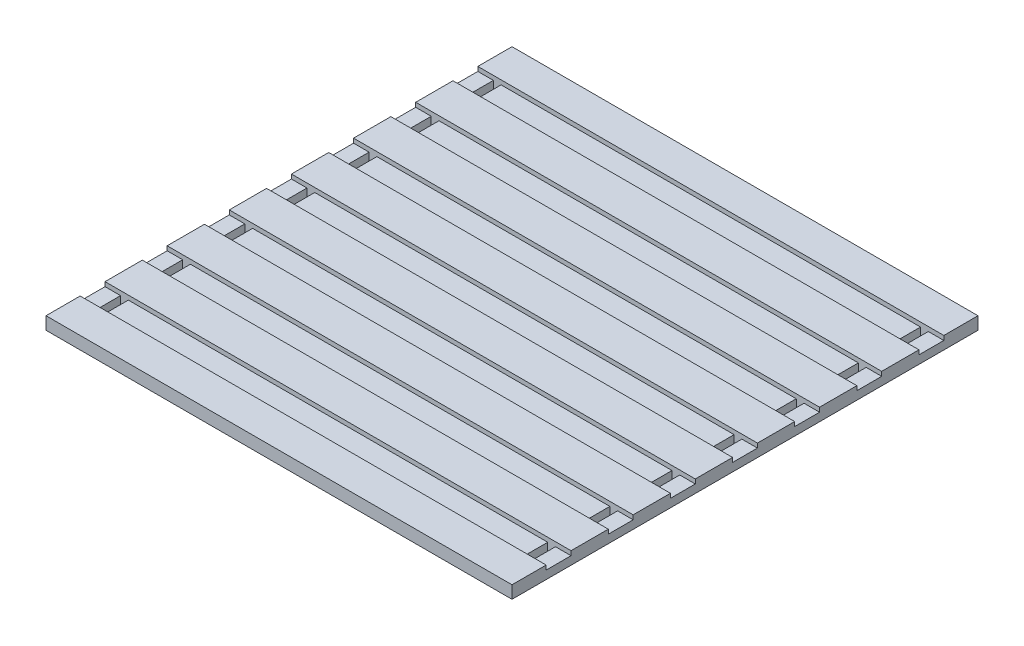
from build123d import *

# Parameters (mm, degrees)
SKETCH1_W           = 190.5
SKETCH1_H           = 190.5
BOSS_EXTRUDE1_DEPTH = 5.159375
SKETCH2_W           = 190.5
SKETCH2_H           = 10.16
CUT_EXTRUDE1_DEPTH  = 1.778
SKETCH3_W           = 3.175
SKETCH3_H           = 10.16
CUT_EXTRUDE3_DEPTH  = 4.381375
LPATTERN1_COUNT     = 7
LPATTERN1_PITCH     = 25.4


with BuildPart() as part:
    # Sketch1 → Boss-Extrude1 (new body)
    with BuildSketch(Plane(origin=(0, 0, 0), x_dir=(1, 0, 0), z_dir=(0, 1, 0))):
        Rectangle(SKETCH1_W, SKETCH1_H)
    extrude(amount=BOSS_EXTRUDE1_DEPTH)

    # Sketch2 → Cut-Extrude1 (cut)
    with BuildSketch(Plane(origin=(0, 5.159375, 0), x_dir=(1, 0, 0), z_dir=(0, 1, 0))):
        with Locations((0, 76.2)):
            Rectangle(SKETCH2_W, SKETCH2_H)
        with Locations((0, 50.8)):
            Rectangle(SKETCH2_W, SKETCH2_H)
        with Locations((0, 25.4)):
            Rectangle(SKETCH2_W, SKETCH2_H)
        Rectangle(SKETCH2_W, SKETCH2_H)
        with Locations((0, -25.4)):
            Rectangle(SKETCH2_W, SKETCH2_H)
        with Locations((0, -50.8)):
            Rectangle(SKETCH2_W, SKETCH2_H)
        with Locations((0, -76.2)):
            Rectangle(SKETCH2_W, SKETCH2_H)
    extrude(amount=-CUT_EXTRUDE1_DEPTH, mode=Mode.SUBTRACT)

    # Sketch3 → Cut-Extrude3 (cut, through all)
    with BuildSketch(Plane(origin=(0, 3.381375, 0), x_dir=(1, 0, 0), z_dir=(0, 1, 0))):
        with Locations((-87.3125, 76.2)):
            Rectangle(SKETCH3_W, SKETCH3_H)
        with Locations((87.3125, 76.2)):
            Rectangle(SKETCH3_W, SKETCH3_H)
    cut_extrude3 = extrude(amount=-CUT_EXTRUDE3_DEPTH, mode=Mode.SUBTRACT)

    # LPattern1: Cut-Extrude3 ×7
    with Locations(*[(0, 0, i * LPATTERN1_PITCH) for i in range(1, LPATTERN1_COUNT)]):
        add(cut_extrude3, mode=Mode.SUBTRACT)


solid = part.part
